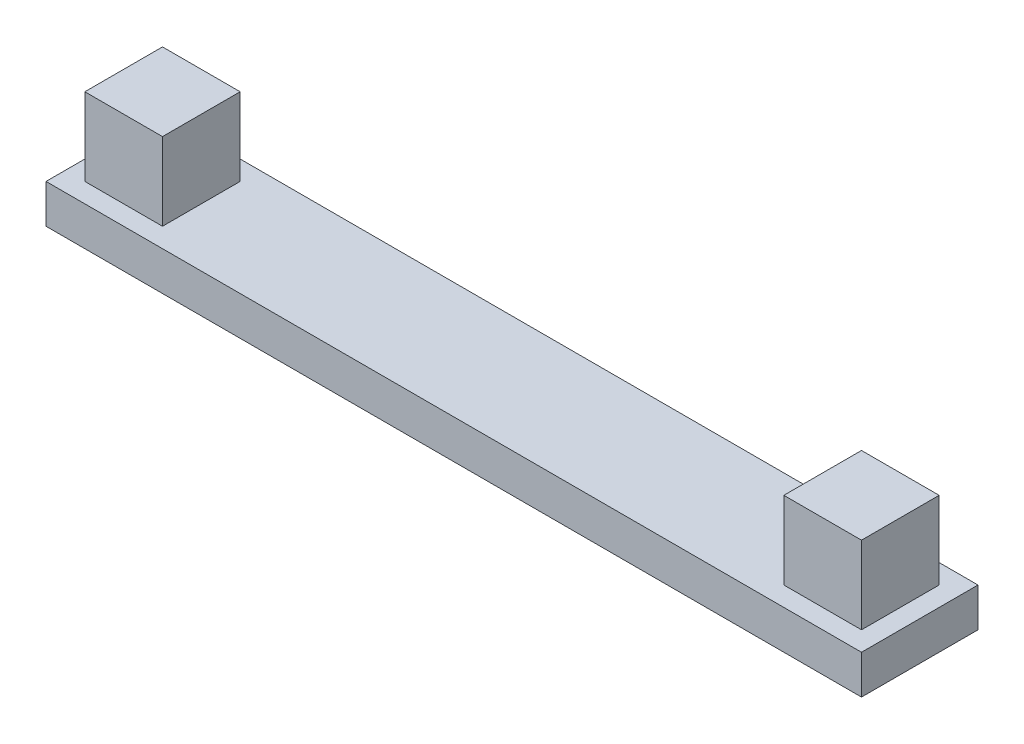
from build123d import *

# Parameters (mm, degrees)
SKETCH1_W           = 21
SKETCH1_H           = 3
SKETCH1_W_2         = 2
SKETCH1_H_2         = 2
BOSS_EXTRUDE1_DEPTH = 1
SKETCH1_3_W         = 2
SKETCH1_3_H         = 2
BOSS_EXTRUDE2_DEPTH = 3


with BuildPart() as part:
    # Sketch1 → Boss-Extrude1 (new body)
    with BuildSketch(Plane(origin=(0, 0, 0), x_dir=(1, 0, 0), z_dir=(0, 1, 0))):
        with Locations((10.5, 1.5)):
            Rectangle(SKETCH1_W, SKETCH1_H)
        with Locations((1.5, 1.5)):
            Rectangle(SKETCH1_W_2, SKETCH1_H_2, mode=Mode.SUBTRACT)
        with Locations((19.5, 1.5)):
            Rectangle(SKETCH1_W_2, SKETCH1_H_2, mode=Mode.SUBTRACT)
    extrude(amount=BOSS_EXTRUDE1_DEPTH)

    # Sketch1_3 → Boss-Extrude2 (add)
    with BuildSketch(Plane(origin=(0, 0, 0), x_dir=(1, 0, 0), z_dir=(0, 1, 0))):
        with Locations((1.5, 1.5)):
            Rectangle(SKETCH1_3_W, SKETCH1_3_H)
        with Locations((19.5, 1.5)):
            Rectangle(SKETCH1_3_W, SKETCH1_3_H)
    extrude(amount=BOSS_EXTRUDE2_DEPTH)


solid = part.part
